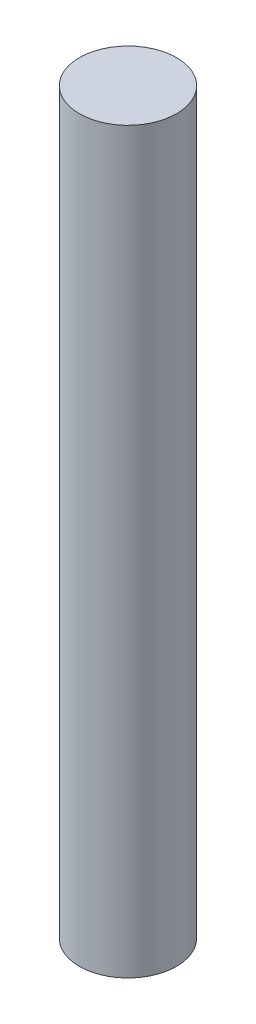
from build123d import *

# Parameters (mm, degrees)
SKETCH1_R           = 2.5
BOSS_EXTRUDE1_DEPTH = 38


with BuildPart() as part:
    # Sketch1 → Boss-Extrude1 (new body)
    with BuildSketch(Plane(origin=(0, 0, 0), x_dir=(1, 0, 0), z_dir=(0, 1, 0))):
        Circle(SKETCH1_R)
    extrude(amount=BOSS_EXTRUDE1_DEPTH)


solid = part.part
